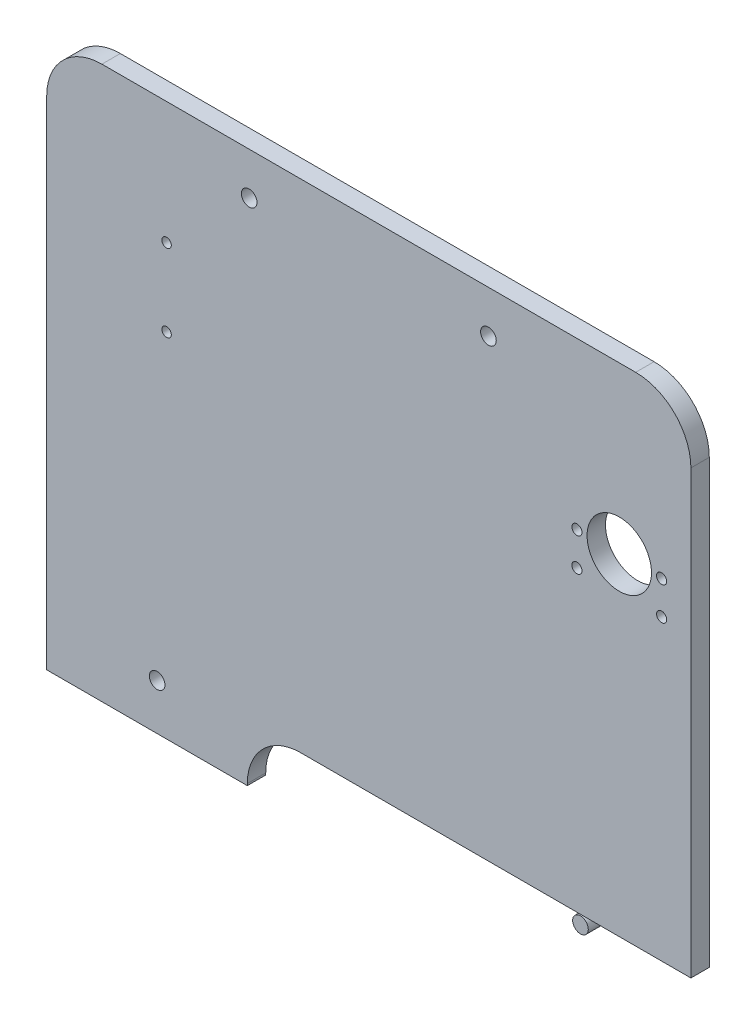
from build123d import *

# Parameters (mm, degrees)
CROQUIS1_W              = 350
CROQUIS1_H              = 300
SALIENTE_EXTRUIR1_DEPTH = 10
REDONDEO4_R             = 30
CROQUIS2_R              = 17.5
CROQUIS2_R_2            = 4.25
CROQUIS2_R_3            = 2.555
CROQUIS2_R_4            = 2.75
CORTAR_EXTRUIR1_DEPTH   = 11


with BuildPart() as part:
    # Croquis1 → Saliente-Extruir1 (new body)
    with BuildSketch(Plane.XY):
        with Locations((-175, 150)):
            Rectangle(CROQUIS1_W, CROQUIS1_H)
    extrude(amount=SALIENTE_EXTRUIR1_DEPTH)

    # Redondeo4
    redondeo4_edges = [part.edges().sort_by_distance(p)[0] for p in [
        (-350, 300, 5),
        (0, 300, 5),
    ]]
    fillet(redondeo4_edges, radius=REDONDEO4_R)

    # Croquis2 → Cortar-Extruir1 (cut, through all)
    with BuildSketch(Plane.XY.offset(10)):
        with Locations((-38.913195394, 210)):
            Circle(CROQUIS2_R)
        with Locations((-290, 25)):
            Circle(CROQUIS2_R_2)
        with Locations((-240, 277)):
            Circle(CROQUIS2_R_2)
        with Locations((-110, 277)):
            Circle(CROQUIS2_R_2)
        with Locations((-355.107, 233.567)):
            Circle(CROQUIS2_R_3)
        with Locations((-284.869, 233.567)):
            Circle(CROQUIS2_R_3)
        with Locations((-284.869, 191.548)):
            Circle(CROQUIS2_R_3)
        with Locations((-355.107, 191.548)):
            Circle(CROQUIS2_R_3)
        with Locations((-15.913195394, 210)):
            Circle(CROQUIS2_R_4)
        with Locations((-15.913195394, 192)):
            Circle(CROQUIS2_R_4)
        with Locations((-61.913195394, 210)):
            Circle(CROQUIS2_R_4)
        with Locations((-61.913195394, 192)):
            Circle(CROQUIS2_R_4)
        with BuildLine():
            Line((-241, 0), (180.991, 0))
            Line((180.991, 0), (180.991, 1))
            ThreePointArc((180.991, 1), (172.497096654, 21.506096654), (151.991, 30))
            Line((151.991, 30), (-212, 30))
            ThreePointArc((-212, 30), (-232.506096654, 21.506096654), (-241, 1))
            Line((-241, 1), (-241, 0))
        make_face()
        with Locations((-60, 25)):
            Circle(CROQUIS2_R_2, mode=Mode.SUBTRACT)
    extrude(amount=-CORTAR_EXTRUIR1_DEPTH, mode=Mode.SUBTRACT)


solid = part.part
